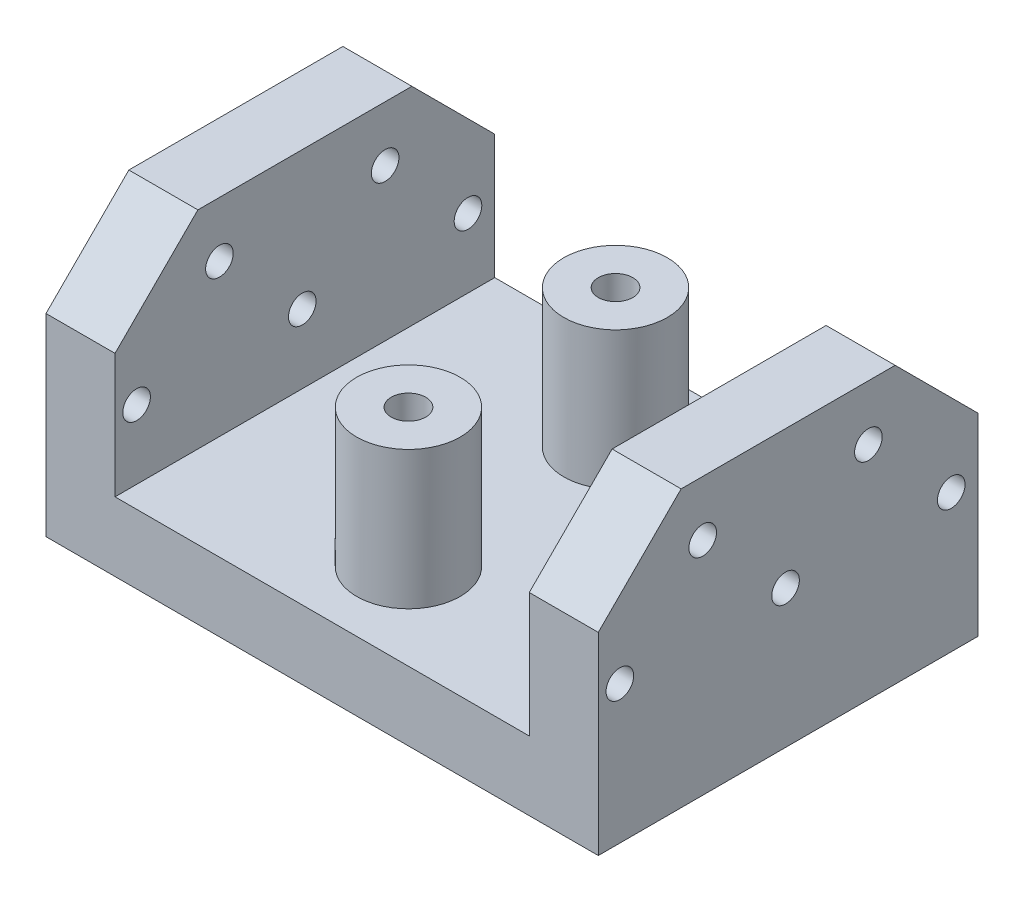
from build123d import *

# Parameters (mm, degrees)
SKETCH1_W           = 80
SKETCH1_H           = 55
BOSS_EXTRUDE1_DEPTH = 10
SKETCH2_W           = 10
SKETCH2_H           = 55
BOSS_EXTRUDE2_DEPTH = 30
SKETCH3_R           = 2
CUT_EXTRUDE1_DEPTH  = 81
SKETCH4_R           = 2.5
CUT_EXTRUDE2_DEPTH  = 30
SKETCH5_R           = 7.5
SKETCH5_R_2         = 2.5
BOSS_EXTRUDE3_DEPTH = 20
SKETCH6_W           = 20.5
SKETCH6_H           = 3.25
CUT_EXTRUDE3_DEPTH  = 5
CUT_EXTRUDE4_DEPTH  = 81


with BuildPart() as part:
    # Sketch1 → Boss-Extrude1 (new body)
    with BuildSketch(Plane(origin=(0, 0, 0), x_dir=(1, 0, 0), z_dir=(0, 1, 0))):
        Rectangle(SKETCH1_W, SKETCH1_H)
    extrude(amount=BOSS_EXTRUDE1_DEPTH)

    # Sketch2 → Boss-Extrude2 (add)
    with BuildSketch(Plane(origin=(0, 10, 0), x_dir=(1, 0, 0), z_dir=(0, 1, 0))):
        with Locations((-35, 0)):
            Rectangle(SKETCH2_W, SKETCH2_H)
        with Locations((35, 0)):
            Rectangle(SKETCH2_W, SKETCH2_H)
    extrude(amount=BOSS_EXTRUDE2_DEPTH)

    # Sketch3 → Cut-Extrude1 (cut, through all)
    with BuildSketch(Plane.ZY.offset(40)):
        with Locations((-23.624192801, 20)):
            Circle(SKETCH3_R)
        with Locations((0.375807199, 20)):
            Circle(SKETCH3_R)
        with Locations((24.375807199, 20)):
            Circle(SKETCH3_R)
        with Locations((-11.624192801, 32)):
            Circle(SKETCH3_R)
        with Locations((12.375807199, 32)):
            Circle(SKETCH3_R)
    extrude(amount=-CUT_EXTRUDE1_DEPTH, mode=Mode.SUBTRACT)

    # Sketch4 → Cut-Extrude2 (cut)
    with BuildSketch(Plane.XZ):
        with Locations((0, 15)):
            Circle(SKETCH4_R)
        with Locations((0, -15)):
            Circle(SKETCH4_R)
    extrude(amount=-CUT_EXTRUDE2_DEPTH, mode=Mode.SUBTRACT)

    # Sketch5 → Boss-Extrude3 (add)
    with BuildSketch(Plane(origin=(0, 10, 0), x_dir=(1, 0, 0), z_dir=(0, 1, 0))):
        with Locations((0, 15)):
            Circle(SKETCH5_R)
        with Locations((0, 15)):
            Circle(SKETCH5_R_2, mode=Mode.SUBTRACT)
        with Locations((0, -15)):
            Circle(SKETCH5_R)
        with Locations((0, -15)):
            Circle(SKETCH5_R_2, mode=Mode.SUBTRACT)
    extrude(amount=BOSS_EXTRUDE3_DEPTH)

    # Sketch6 → Cut-Extrude3 (cut)
    with BuildSketch(Plane.XZ):
        with Locations((0, 9.125)):
            Rectangle(SKETCH6_W, SKETCH6_H)
        with Locations((0, -9.125)):
            Rectangle(SKETCH6_W, SKETCH6_H)
    extrude(amount=-CUT_EXTRUDE3_DEPTH, mode=Mode.SUBTRACT)

    # Sketch7 → Cut-Extrude4 (cut, through all)
    with BuildSketch(Plane(origin=(40, 0, 0), x_dir=(0, 0, -1), z_dir=(1, 0, 0))):
        Polygon((-27.5, 28), (-15.5, 40), (-27.5, 40), align=None)
        Polygon((15.5, 40), (27.5, 28), (27.5, 40), align=None)
    extrude(amount=-CUT_EXTRUDE4_DEPTH, mode=Mode.SUBTRACT)


solid = part.part
